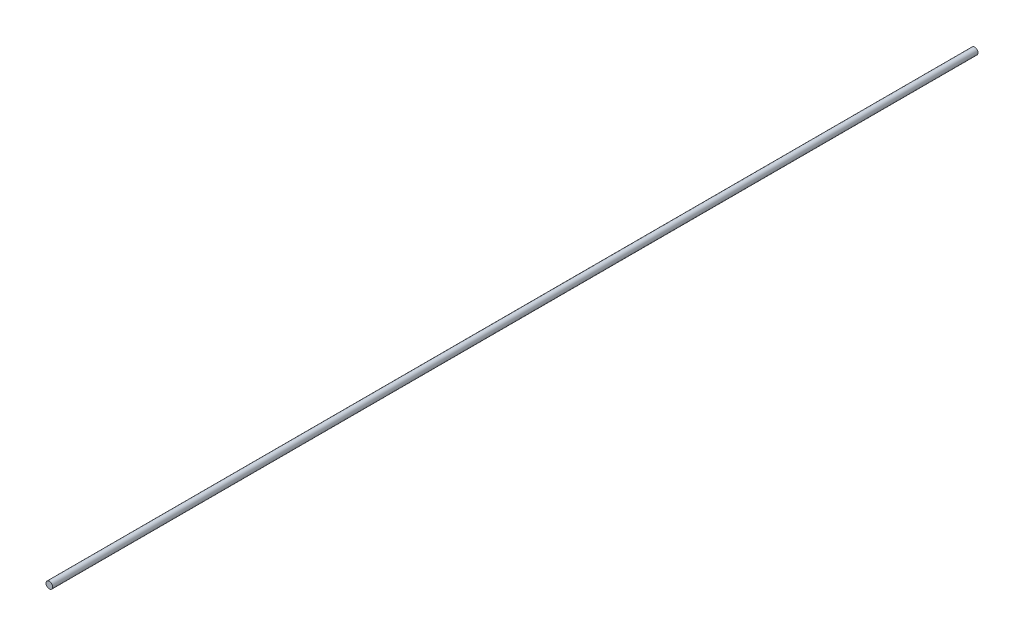
from build123d import *

# Parameters (mm, degrees)
SKETCH1_R           = 1.15
BOSS_EXTRUDE1_DEPTH = 319


with BuildPart() as part:
    # Sketch1 → Boss-Extrude1 (new body)
    with BuildSketch(Plane.XY):
        Circle(SKETCH1_R)
    extrude(amount=BOSS_EXTRUDE1_DEPTH)


solid = part.part
